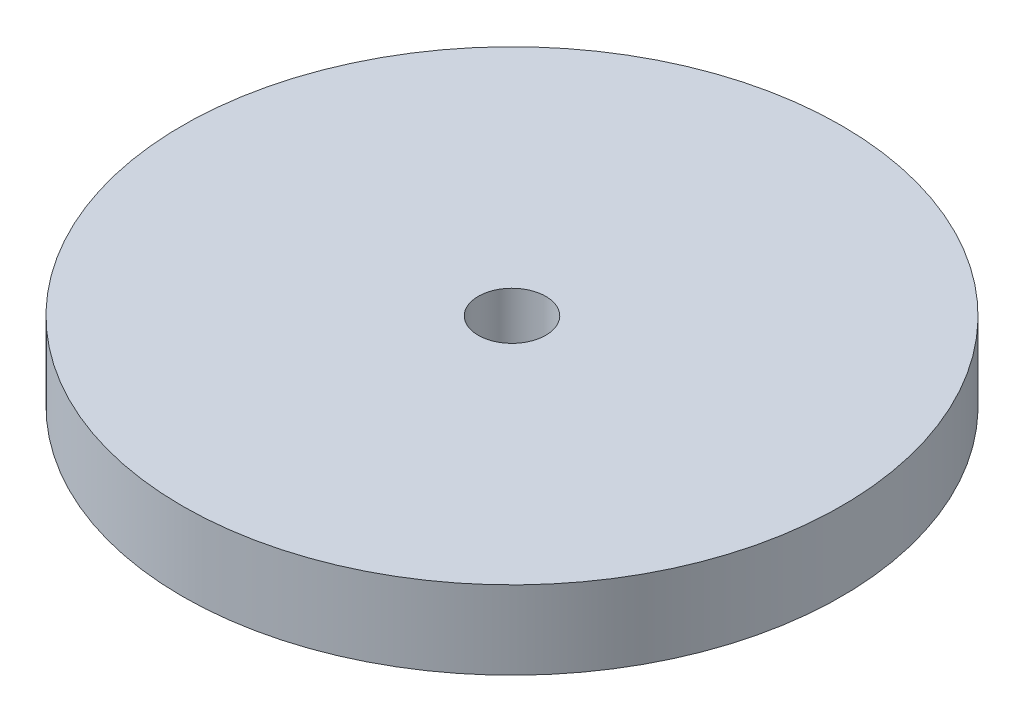
from build123d import *

# Parameters (mm, degrees)
SKETCH1_R           = 40
SKETCH1_R_2         = 4.1
BOSS_EXTRUDE1_DEPTH = 9.5


with BuildPart() as part:
    # Sketch1 → Boss-Extrude1 (new body)
    with BuildSketch(Plane(origin=(0, 0, 0), x_dir=(1, 0, 0), z_dir=(0, 1, 0))):
        Circle(SKETCH1_R)
        Circle(SKETCH1_R_2, mode=Mode.SUBTRACT)
    extrude(amount=BOSS_EXTRUDE1_DEPTH)


solid = part.part
